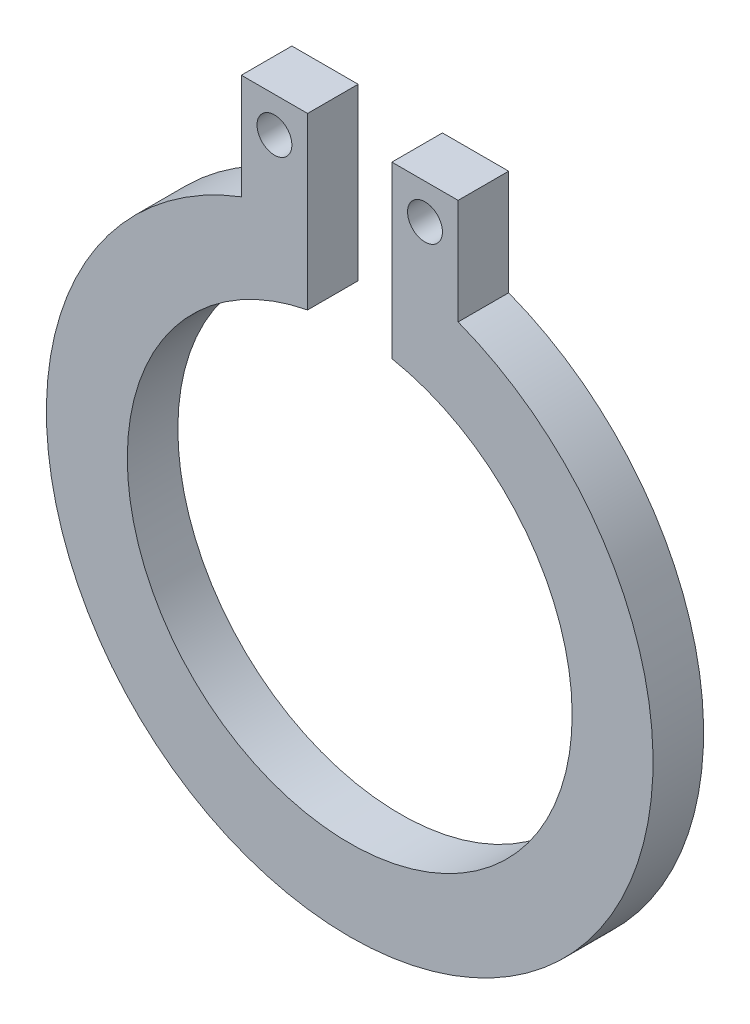
from build123d import *

# Parameters (mm, degrees)
SZKIC1_R                    = 0.172416741
DODANIE_WYCI_GNI_CIE1_DEPTH = 0.5


with BuildPart() as part:
    # Szkic1 → Dodanie-wyciągnięcie1 (new body)
    with BuildSketch(Plane.XY):
        with BuildLine():
            Line((1.072016687, 2.801924379), (1.072016687, 3.843679809))
            Line((1.072016687, 3.843679809), (0.416833072, 3.843679809))
            Line((0.416833072, 3.843679809), (0.416833072, 2.160150502))
            ThreePointArc((0.416833072, 2.160150502), (0, -2.2), (-0.416833072, 2.160150502))
            Line((-0.416833072, 2.160150502), (-0.416833072, 3.843679809))
            Line((-0.416833072, 3.843679809), (-1.072016687, 3.843679809))
            Line((-1.072016687, 3.843679809), (-1.072016687, 2.801924379))
            ThreePointArc((-1.072016687, 2.801924379), (0, -3), (1.072016687, 2.801924379))
        make_face()
        with Locations((0.74442488, 3.495160541)):
            Circle(SZKIC1_R, mode=Mode.SUBTRACT)
        with Locations((-0.74442488, 3.495160541)):
            Circle(SZKIC1_R, mode=Mode.SUBTRACT)
    extrude(amount=DODANIE_WYCI_GNI_CIE1_DEPTH)


solid = part.part
